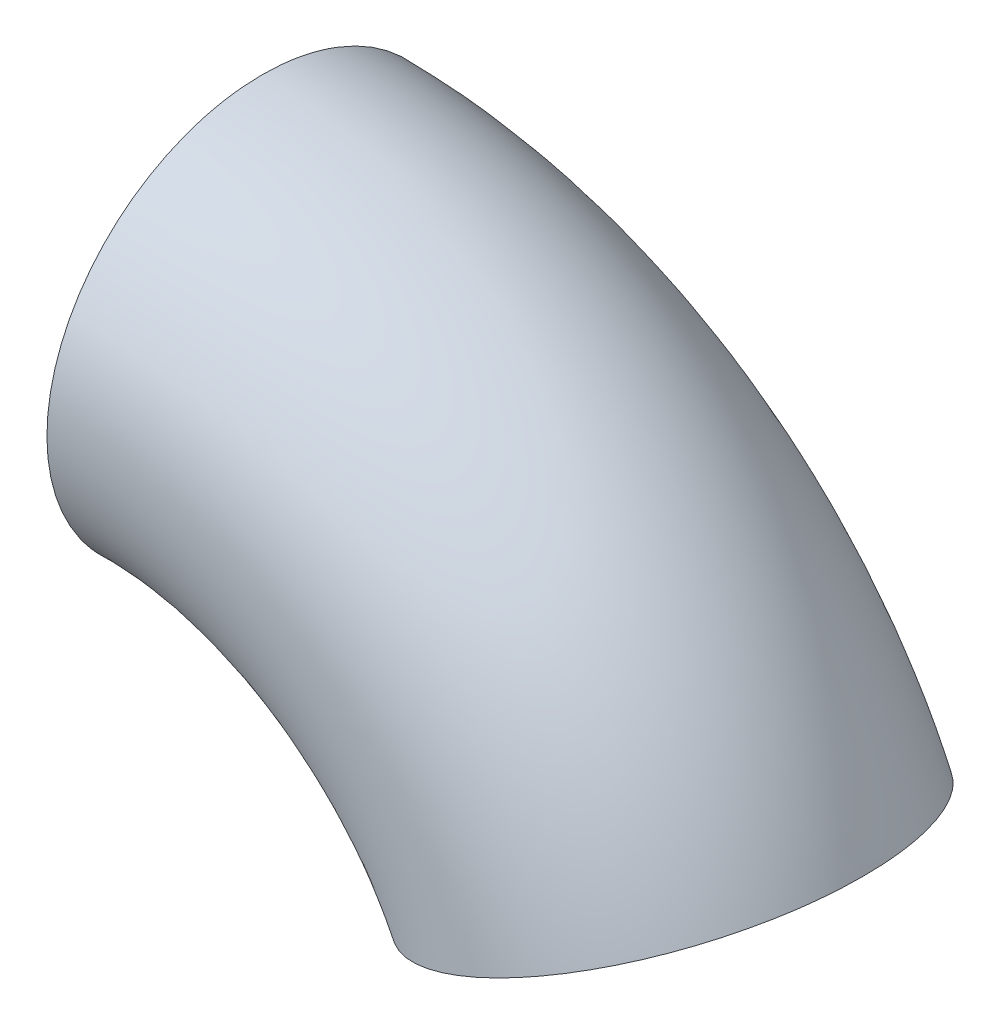
from build123d import *

# Parameters (mm, degrees)
SKETCH2_R   = 20
SKETCH2_R_2 = 19.5


with BuildPart() as part:
    # Sweep2: sweep along a path in Sketch1
    with BuildLine(Plane.XY) as sweep2_path:
        ThreePointArc((0, 0), (24.15426469, -7.03196743), (40.759551488, -25.930155677))
    # Sketch2 → Sweep2 (sweep)
    with BuildSketch(Plane(origin=(0, 0, 0), x_dir=(0, 0, -1), z_dir=(0.999013765, -0.044401549, 0))):
        Circle(SKETCH2_R)
        Circle(SKETCH2_R_2, mode=Mode.SUBTRACT)
    sweep(path=sweep2_path.line)


solid = part.part
